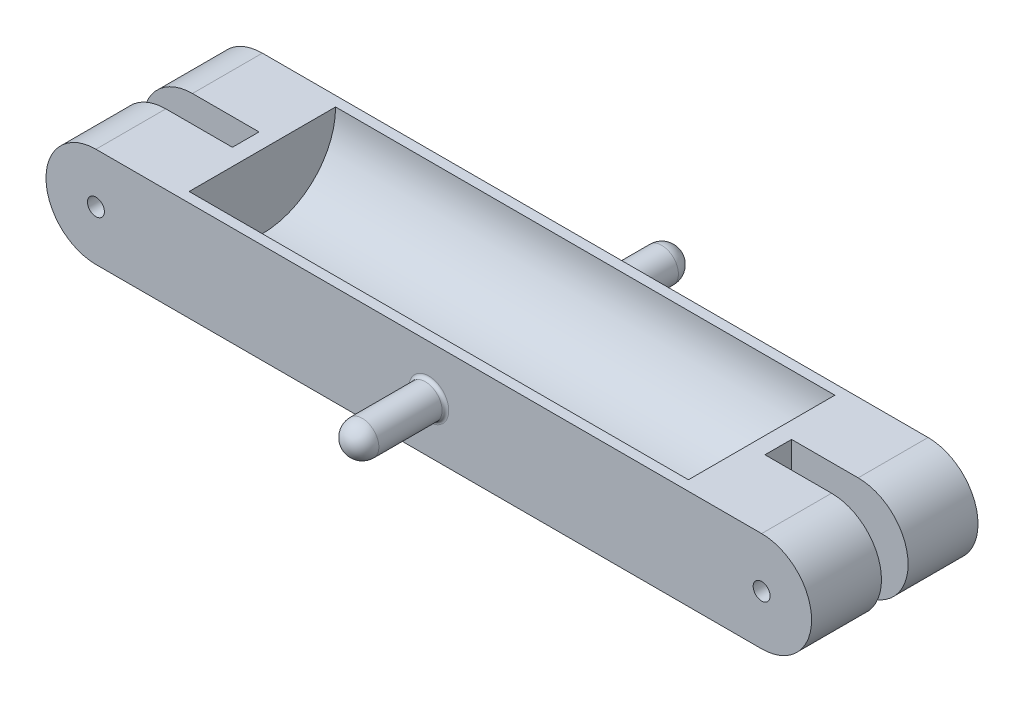
from build123d import *

# Parameters (mm, degrees)
SKETCH2_R           = 2.55
BOSS_EXTRUDE1_DEPTH = 50
SKETCH6_W           = 35
SKETCH6_H           = 8
CUT_EXTRUDE3_DEPTH  = 31
CUT_EXTRUDE6_DEPTH  = 75
SKETCH9_R           = 5
BOSS_EXTRUDE2_DEPTH = 20
REVOLVE1_ANGLE      = 180
FILLET2_R           = 1


with BuildPart() as part:
    # Sketch2 → Boss-Extrude1 (new body)
    with BuildSketch(Plane.XY):
        with BuildLine():
            Line((0, 15), (100, 15))
            ThreePointArc((100, 15), (115, 0), (100, -15))
            Line((100, -15), (0, -15))
            Line((0, -15), (0, 15))
        make_face()
        with Locations((100, 0)):
            Circle(SKETCH2_R, mode=Mode.SUBTRACT)
    boss_extrude1 = extrude(amount=BOSS_EXTRUDE1_DEPTH)

    # Sketch6 → Cut-Extrude3 (cut, through all)
    with BuildSketch(Plane(origin=(0, 15, 0), x_dir=(1, 0, 0), z_dir=(0, 1, 0))):
        with Locations((97.5, -25)):
            Rectangle(SKETCH6_W, SKETCH6_H)
    cut_extrude3 = extrude(amount=-CUT_EXTRUDE3_DEPTH, mode=Mode.SUBTRACT)

    # Sketch7 → Cut-Extrude6 (cut)
    with BuildSketch(Plane.ZY):
        with BuildLine():
            Line((3, 15), (47, 15))
            ThreePointArc((47, 15), (25, -7), (3, 15))
        make_face()
    cut_extrude6 = extrude(amount=-CUT_EXTRUDE6_DEPTH, mode=Mode.SUBTRACT)

    # Mirror3: Boss-Extrude1, Cut-Extrude3, Cut-Extrude6 across plane
    add(boss_extrude1.mirror(Plane(origin=(0, -15, 50), x_dir=(0, 0, 1), z_dir=(-1, 0, 0))))
    add(cut_extrude3.mirror(Plane(origin=(0, -15, 50), x_dir=(0, 0, 1), z_dir=(-1, 0, 0))), mode=Mode.SUBTRACT)
    add(cut_extrude6.mirror(Plane(origin=(0, -15, 50), x_dir=(0, 0, 1), z_dir=(-1, 0, 0))), mode=Mode.SUBTRACT)

    # Sketch9 → Boss-Extrude2 (add)
    with BuildSketch(Plane.XY.offset(50)):
        Circle(SKETCH9_R)
    boss_extrude2 = extrude(amount=BOSS_EXTRUDE2_DEPTH)

    # Sketch12 → Revolve1 (revolve)
    with BuildSketch(Plane.XY.offset(70)):
        with BuildLine():
            Line((0, -5), (0, 5))
            ThreePointArc((0, 5), (5, 0), (0, -5))
        make_face()
    revolve1 = revolve(axis=Axis((0, -5, 70), (0, -1, 0)), revolution_arc=REVOLVE1_ANGLE)

    # Mirror4: Boss-Extrude2, Revolve1 across plane
    add(boss_extrude2.mirror(Plane(origin=(75, -7, 25), x_dir=(1, 0, 0), z_dir=(0, 0, 1))))
    add(revolve1.mirror(Plane(origin=(75, -7, 25), x_dir=(1, 0, 0), z_dir=(0, 0, 1))))

    # Fillet2
    fillet2_edges = [part.edges().sort_by_distance(p)[0] for p in [
        (-5, 0, 50),
        (-5, 0, 0),
    ]]
    fillet(fillet2_edges, radius=FILLET2_R)


solid = part.part
